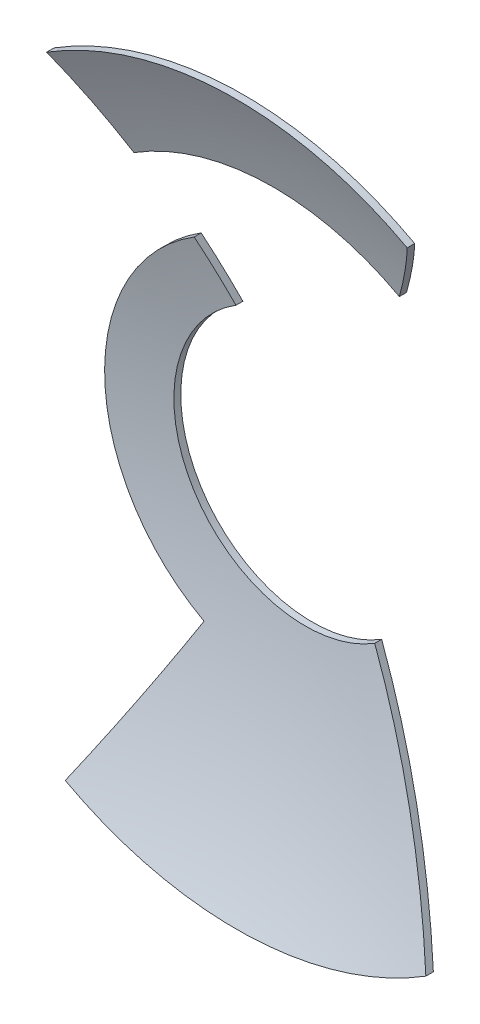
from build123d import *

# Parameters (mm, degrees)
REVOLVE_1_ANGLE     = 180
SHELL_1_T           = 1
SKETCH_2_OUTSIDE_W  = 330.12
SKETCH_2_OUTSIDE_H  = 330.12
CUT_EXTRUDE_1_DEPTH = 181


with BuildPart() as part:
    # 草图3 → 旋转1 (revolve)
    with BuildSketch(Plane.XY):
        with BuildLine():
            Line((0, -125.2), (0, 125.2))
            ThreePointArc((0, 125.2), (-125.2, 0), (0, -125.2))
        make_face()
    revolve(axis=Axis((0, 183.556728616, 0), (0, -1, 0)), revolution_arc=REVOLVE_1_ANGLE)

    # 抽壳1
    shell_1_openings = [part.faces().sort_by_distance(p)[0] for p in [
        (0, 0, 0),
    ]]
    offset(amount=SHELL_1_T, openings=shell_1_openings)

    # 草图2 outside → 切除-拉伸1 (cut)
    with BuildSketch(Plane.XY):
        Rectangle(SKETCH_2_OUTSIDE_W, SKETCH_2_OUTSIDE_H)
        with BuildLine():
            Line((-27.797446952, 44.75785495), (-20.46258832, 32.947686222))
            ThreePointArc((-20.46258832, 32.947686222), (-1.162793695, 38.767453604), (18.451109461, 34.114866375))
            Line((18.451109461, 34.114866375), (25.064949186, 46.34341333))
            ThreePointArc((25.064949186, 46.34341333), (-1.579599587, 52.663730422), (-27.797446952, 44.75785495))
        make_face(mode=Mode.SUBTRACT)
        with BuildLine():
            Line((-14.665704624, 23.613876534), (-10.170028494, 16.375196649))
            ThreePointArc((-10.170028494, 16.375196649), (-16.375196649, -10.170028494), (10.170028494, -16.375196649))
            Line((10.170028494, -16.375196649), (27.797446952, -44.75785495))
            ThreePointArc((27.797446952, -44.75785495), (1.579599587, -52.663730422), (-25.064949186, -46.34341333))
            Line((-25.064949186, -46.34341333), (-13.224061253, -24.450404108))
            ThreePointArc((-13.224061253, -24.450404108), (-27.784951477, -0.833383764), (-14.665704624, 23.613876534))
        make_face(mode=Mode.SUBTRACT)
    extrude(amount=-CUT_EXTRUDE_1_DEPTH, mode=Mode.SUBTRACT)


with BuildPart() as cut_extrude_1_piece_1:
    # of the separate pieces the step leaves, piece 1, a body of its own (cut_extrude_1_pieces)
    add(part.part.solids().sort_by_distance((-13.224061253, -24.450404108, -122.075148752))[0])


with BuildPart() as cut_extrude_1_piece_2:
    # of the separate pieces the step leaves, piece 2, a body of its own (cut_extrude_1_pieces)
    add(part.part.solids().sort_by_distance((-20.46258832, 32.947686222, -119.041053641))[0])


solid = Compound([cut_extrude_1_piece_1.part, cut_extrude_1_piece_2.part])
